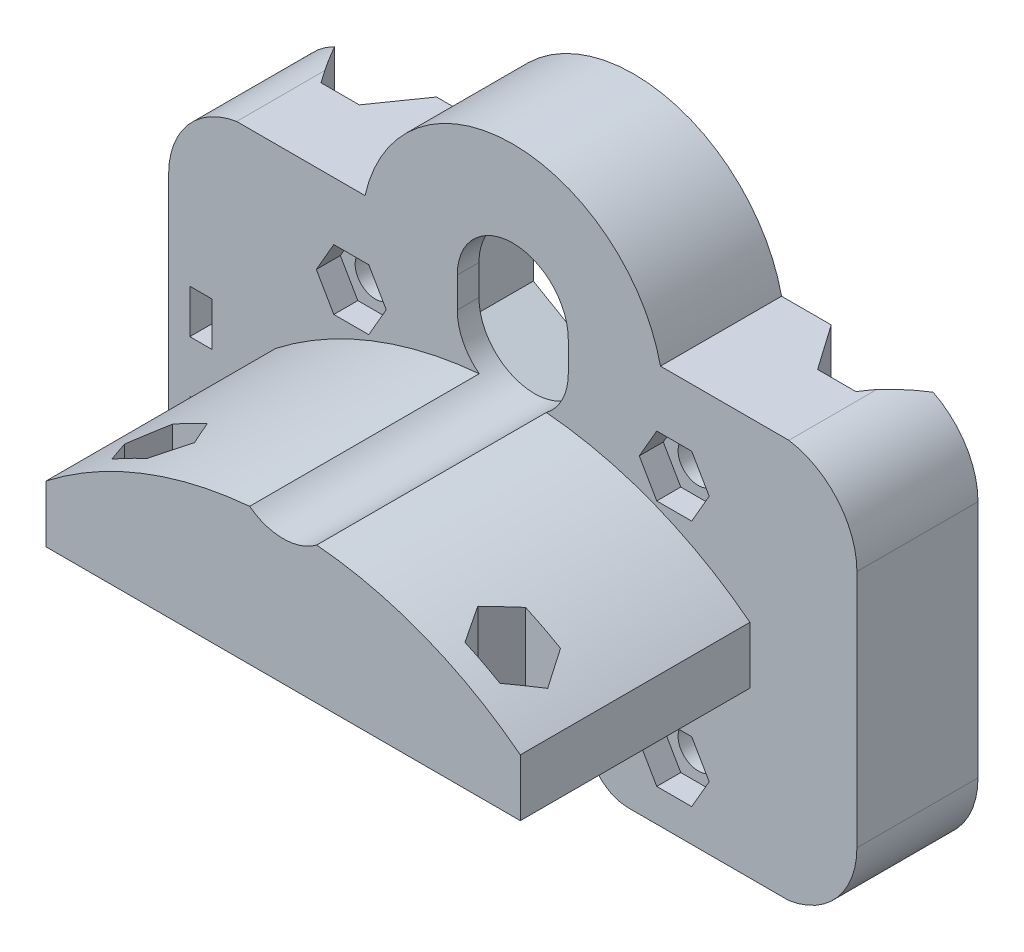
from build123d import *

# Parameters (mm, degrees)
SKETCH1_R                = 2.000043321
SKETCH1_R_2              = 2.000014119
BOSS_EXTRUDE1_DEPTH      = 7.5
BOSS_EXTRUDE1_DEPTH_BACK = 4.5
CUT_EXTRUDE2_DEPTH       = 13
SKETCH3_R                = 2.000014119
SKETCH3_R_2              = 2.000043321
CUT_EXTRUDE3_DEPTH       = 2.38
SKETCH6_W                = 47
SKETCH6_H                = 5.65
BOSS_EXTRUDE2_DEPTH      = 22.75
SKETCH9_R                = 1.8
CUT_EXTRUDE5_DEPTH       = 22.75
CUT_EXTRUDE5_DEPTH_BACK  = 23.750023286
CUT_EXTRUDE6_DEPTH       = 22.75
CUT_EXTRUDE6_DEPTH_BACK  = 4.1004
SKETCH11_R               = 1.250008473
SKETCH11_R_2             = 1.24999389
CUT_EXTRUDE8_DEPTH       = 6.1
SKETCH13_W               = 2.2
SKETCH13_H               = 4.330124
SKETCH13_H_2             = 4.33016
CUT_EXTRUDE9_DEPTH       = 5.3
CUT_EXTRUDE10_DEPTH      = 9.85


with BuildPart() as part:
    # Sketch1 → Boss-Extrude1 (new body, two sides)
    with BuildSketch(Plane.XY) as boss_extrude1_sk:
        with BuildLine():
            ThreePointArc((27.3591, -22.750023286), (32.18573506, -20.04264062), (34.100000001, -14.850154064))
            Line((34.100000001, -14.850154064), (34.100000001, 8.850156137))
            ThreePointArc((34.100000001, 8.850156137), (32.18573506, 14.042642693), (27.3591, 16.750025358))
            Line((27.3591, 16.750025358), (14.6356, 16.750025358))
            ThreePointArc((14.6356, 16.750025358), (0, 28.500025358), (-14.6356, 16.750025358))
            Line((-14.6356, 16.750025358), (-27.3591, 16.750025358))
            ThreePointArc((-27.3591, 16.750025358), (-32.18573506, 14.042642693), (-34.100000001, 8.850156137))
            Line((-34.100000001, 8.850156137), (-34.100000001, -14.850154064))
            ThreePointArc((-34.100000001, -14.850154064), (-32.18573506, -20.04264062), (-27.3591, -22.750023286))
            Line((-27.3591, -22.750023286), (-11.500037792, -22.750023286))
            ThreePointArc((-11.500037792, -22.750023286), (-8.671570628, -21.578433826), (-7.499981167, -18.749966661))
            Line((-7.499981167, -18.749966661), (-7.499981167, -16.089239323))
            ThreePointArc((-7.499981167, -16.089239323), (-7.500113179, -16.044739987), (-7.499981167, -16.000240651))
            ThreePointArc((-7.499981167, -16.000240651), (0, -8.544626807), (7.499981167, -16.000240651))
            ThreePointArc((7.499981167, -16.000240651), (7.500113179, -16.044739987), (7.499981167, -16.089239323))
            Line((7.499981167, -16.089239323), (7.499981167, -18.749966661))
            ThreePointArc((7.499981167, -18.749966661), (8.671570628, -21.578433826), (11.500037792, -22.750023286))
            Line((11.500037792, -22.750023286), (27.3591, -22.750023286))
        make_face()
        with Locations((-16.000068831, -16.5)):
            Circle(SKETCH1_R, mode=Mode.SUBTRACT)
        with Locations((16.000068831, -16.5)):
            Circle(SKETCH1_R, mode=Mode.SUBTRACT)
        with Locations((-16.000068831, 7.999981023)):
            Circle(SKETCH1_R_2, mode=Mode.SUBTRACT)
        with Locations((16.000068831, 7.999981023)):
            Circle(SKETCH1_R_2, mode=Mode.SUBTRACT)
    extrude(amount=BOSS_EXTRUDE1_DEPTH)
    extrude(boss_extrude1_sk.sketch, amount=-BOSS_EXTRUDE1_DEPTH_BACK)

    # Sketch4 → Cut-Extrude2 (cut, through all)
    with BuildSketch(Plane.XY.offset(7.5)):
        with BuildLine():
            Line((5.5, 11.5), (5.5, 14.5))
            ThreePointArc((5.5, 14.5), (0, 20), (-5.5, 14.5))
            Line((-5.5, 14.5), (-5.5, 11.5))
            ThreePointArc((-5.5, 11.5), (0, 6), (5.5, 11.5))
        make_face()
    extrude(amount=-CUT_EXTRUDE2_DEPTH, mode=Mode.SUBTRACT)

    # Sketch3 → Cut-Extrude3 (cut)
    with BuildSketch(Plane.XY.offset(7.5)):
        Polygon((-14.268018024, 10.999981023), (-17.732119639, 10.999981023), (-19.464170446, 7.999981023), (-17.732119639, 4.999981023), (-14.268018024, 4.999981023), (-12.535967216, 7.999981023), align=None)
        with Locations((-16.000068831, 7.999981023)):
            Circle(SKETCH3_R, mode=Mode.SUBTRACT)
        Polygon((14.268018024, 10.999981023), (17.732119639, 10.999981023), (19.464170446, 7.999981023), (17.732119639, 4.999981023), (14.268018024, 4.999981023), (12.535967216, 7.999981023), align=None)
        with Locations((16.000068831, 7.999981023)):
            Circle(SKETCH3_R, mode=Mode.SUBTRACT)
        Polygon((-14.268018024, -19.500018977), (-17.732119639, -19.500018977), (-19.464170446, -16.500018977), (-17.732119639, -13.500018977), (-14.268018024, -13.500018977), (-12.535967216, -16.500018977), align=None)
        with Locations((-16.000068831, -16.5)):
            Circle(SKETCH3_R_2, mode=Mode.SUBTRACT)
        Polygon((12.535967216, -16.500018977), (14.268018024, -19.500018977), (17.732119639, -19.500018977), (19.464170446, -16.500018977), (17.732119639, -13.500018977), (14.268018024, -13.500018977), align=None)
        with Locations((16.000068831, -16.5)):
            Circle(SKETCH3_R_2, mode=Mode.SUBTRACT)
    extrude(amount=-CUT_EXTRUDE3_DEPTH, mode=Mode.SUBTRACT)

    # Sketch6 → Boss-Extrude2 (add)
    with BuildSketch(Plane.XY.offset(7.5)):
        with Locations((0, -3.625)):
            Rectangle(SKETCH6_W, SKETCH6_H)
        with BuildLine():
            Line((-23.5, -0.8), (23.5, -0.8))
            ThreePointArc((23.5, -0.8), (13.984131025, 4.616883926), (3.324005419, 7.118106805))
            ThreePointArc((3.324005419, 7.118106805), (0, 6), (-3.324005419, 7.118106805))
            ThreePointArc((-3.324005419, 7.118106805), (-13.984131025, 4.616883926), (-23.5, -0.8))
        make_face()
    extrude(amount=BOSS_EXTRUDE2_DEPTH)

    # Sketch9 → Cut-Extrude5 (cut, two sides)
    with BuildSketch(Plane(origin=(0, 0, 0), x_dir=(1, 0, 0), z_dir=(0, 1, 0))) as cut_extrude5_sk:
        Polygon((19.555132158, 4.5), (22.70606608, 0), (26.49606608, 0), (29.647000001, 4.5), align=None)
        Polygon((-19.555132158, 4.5), (-29.647000001, 4.5), (-26.49606608, 0), (-22.70606608, 0), align=None)
        with Locations((17.5, -25)):
            Circle(SKETCH9_R)
        with Locations((-17.5, -25)):
            Circle(SKETCH9_R)
    extrude(amount=CUT_EXTRUDE5_DEPTH, mode=Mode.SUBTRACT)
    extrude(cut_extrude5_sk.sketch, amount=-CUT_EXTRUDE5_DEPTH_BACK, mode=Mode.SUBTRACT)

    # Sketch9_7 → Cut-Extrude6 (cut, two sides)
    with BuildSketch(Plane(origin=(0, 0, 0), x_dir=(1, 0, 0), z_dir=(0, 1, 0))) as cut_extrude6_sk:
        Polygon((-19.232050808, -22), (-20.964101615, -25), (-19.232050808, -28), (-15.767949192, -28), (-14.035898385, -25), (-15.767949192, -22), align=None)
        Polygon((20.964101615, -25), (19.232050808, -28), (15.767949192, -28), (14.035898385, -25), (15.767949192, -22), (19.232050808, -22), align=None)
    extrude(amount=CUT_EXTRUDE6_DEPTH, mode=Mode.SUBTRACT)
    extrude(cut_extrude6_sk.sketch, amount=-CUT_EXTRUDE6_DEPTH_BACK, mode=Mode.SUBTRACT)

    # Sketch11 → Cut-Extrude8 (cut)
    with BuildSketch(Plane.ZY.offset(34.100000001)):
        with Locations((3.549979666, -1.86999177)):
            Circle(SKETCH11_R)
        with Locations((3.549979666, -11.329991983)):
            Circle(SKETCH11_R_2)
    extrude(amount=-CUT_EXTRUDE8_DEPTH, mode=Mode.SUBTRACT)

    # Sketch13 → Cut-Extrude9 (cut)
    with BuildSketch(Plane.XY.offset(7.5)):
        with Locations((-30.9, -1.869998)):
            Rectangle(SKETCH13_W, SKETCH13_H)
        with Locations((-30.9, -11.33002)):
            Rectangle(SKETCH13_W, SKETCH13_H_2)
    extrude(amount=-CUT_EXTRUDE9_DEPTH, mode=Mode.SUBTRACT)

    # Sketch15 → Cut-Extrude10 (cut)
    with BuildSketch(Plane(origin=(0, 0, -4.5), x_dir=(-1, 0, 0), z_dir=(0, 0, -1))):
        Polygon((-7.2e-08, 26), (-9.95929, 20.25), (-9.95929, 5.75), (7.2e-08, 1.24e-07), (9.95929, 5.75), (9.95929, 20.25), align=None)
    extrude(amount=-CUT_EXTRUDE10_DEPTH, mode=Mode.SUBTRACT)


solid = part.part
